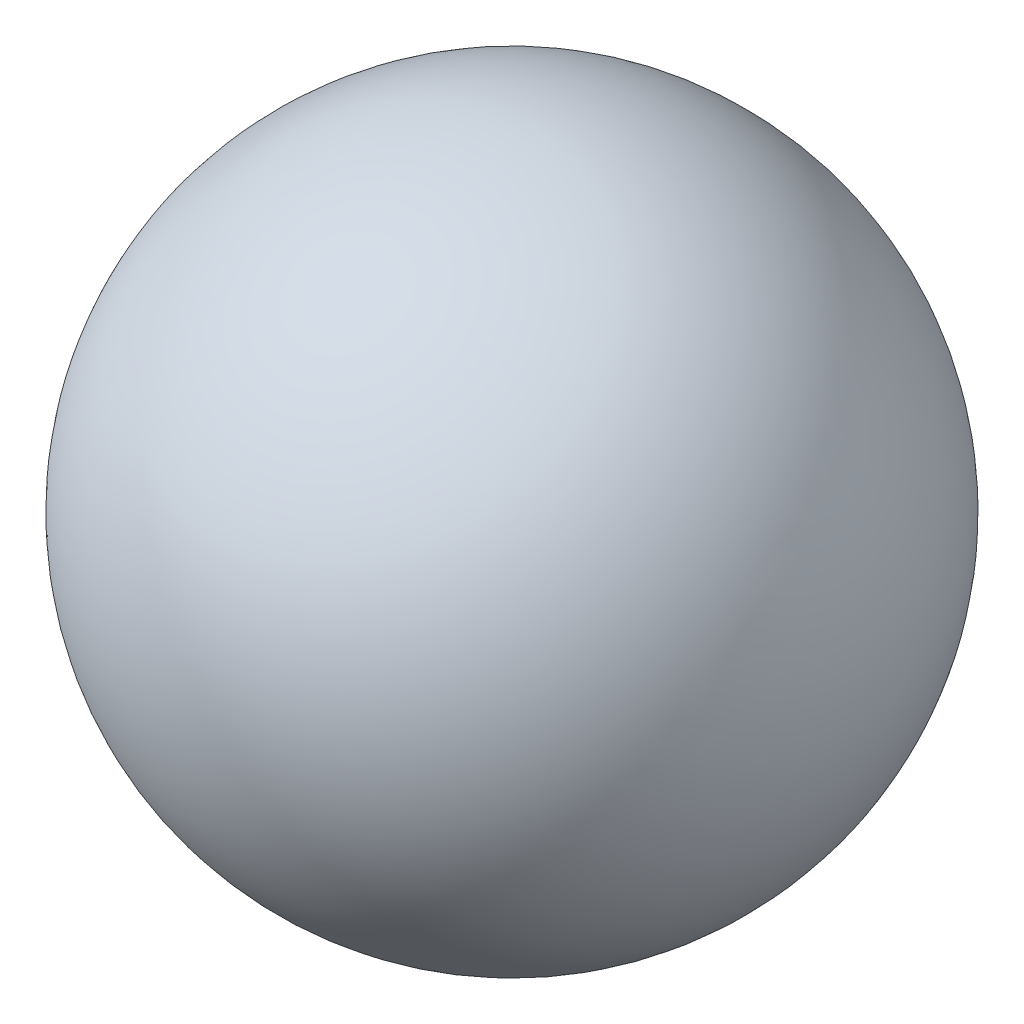
from build123d import *


with BuildPart() as part:
    # Sketch1 → Revolve1 (revolve)
    with BuildSketch(Plane.XY):
        with BuildLine():
            Line((18.034, 0), (-18.034, 0))
            ThreePointArc((-18.034, 0), (0, -18.034), (18.034, 0))
        make_face()
    revolve(axis=Axis((-31.487292341, 0, 0), (1, 0, 0)))


solid = part.part
